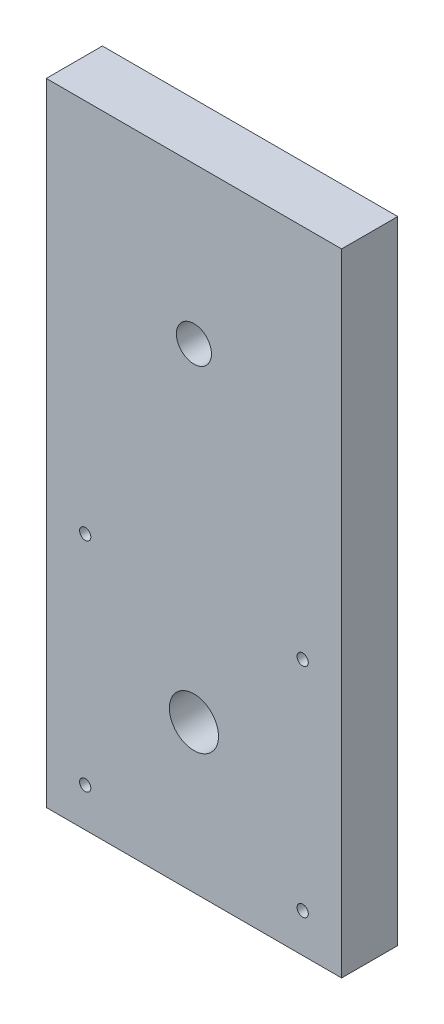
from build123d import *

# Parameters (mm, degrees)
SKETCH2_W           = 42.1
SKETCH2_H           = 90
SKETCH2_R           = 11.75
BOSS_EXTRUDE1_DEPTH = 3
SKETCH3_W           = 42.1
SKETCH3_H           = 90
SKETCH3_R           = 3.5
BOSS_EXTRUDE2_DEPTH = 5
SKETCH6_R           = 0.8
CUT_EXTRUDE1_DEPTH  = 9
SKETCH7_R           = 2.5
CUT_EXTRUDE2_DEPTH  = 9


with BuildPart() as part:
    # Sketch2 → Boss-Extrude1 (new body)
    with BuildSketch(Plane.XY):
        with Locations((0, 23.95)):
            Rectangle(SKETCH2_W, SKETCH2_H)
        Circle(SKETCH2_R, mode=Mode.SUBTRACT)
    extrude(amount=BOSS_EXTRUDE1_DEPTH)

    # Sketch3 → Boss-Extrude2 (add)
    with BuildSketch(Plane.XY.offset(3)):
        with Locations((0, 23.95)):
            Rectangle(SKETCH3_W, SKETCH3_H)
        Circle(SKETCH3_R, mode=Mode.SUBTRACT)
    extrude(amount=BOSS_EXTRUDE2_DEPTH)

    # Sketch6 → Cut-Extrude1 (cut, through all)
    with BuildSketch(Plane.XY.offset(8)):
        with Locations((-15.5, 15.5)):
            Circle(SKETCH6_R)
        with Locations((-15.5, -15.5)):
            Circle(SKETCH6_R)
        with Locations((15.5, 15.5)):
            Circle(SKETCH6_R)
        with Locations((15.5, -15.5)):
            Circle(SKETCH6_R)
    extrude(amount=-CUT_EXTRUDE1_DEPTH, mode=Mode.SUBTRACT)

    # Sketch7 → Cut-Extrude2 (cut, through all)
    with BuildSketch(Plane.XY.offset(8)):
        with Locations((0, 46.707876994)):
            Circle(SKETCH7_R)
    extrude(amount=-CUT_EXTRUDE2_DEPTH, mode=Mode.SUBTRACT)


solid = part.part
